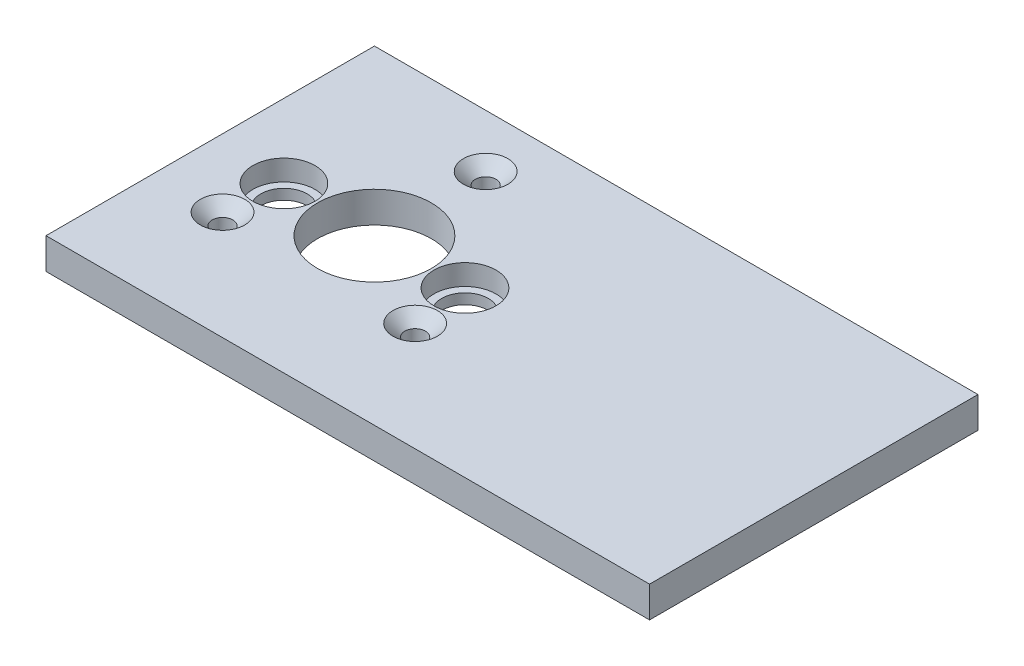
from build123d import *

# Parameters (mm, degrees)
SKETCH1_W           = 116.684502442
SKETCH1_H           = 63.5
SKETCH1_R           = 11
SKETCH1_R_2         = 2
SKETCH1_R_3         = 6
BOSS_EXTRUDE1_DEPTH = 6
CHAMFER1_SIZE       = 2.3
SKETCH2_R           = 6
SKETCH2_R_2         = 4.5
BOSS_EXTRUDE2_DEPTH = 2


with BuildPart() as part:
    # Sketch1 → Boss-Extrude1 (new body)
    with BuildSketch(Plane(origin=(0, 0, 0), x_dir=(1, 0, 0), z_dir=(0, 1, 0))):
        with Locations((26.592251221, 0)):
            Rectangle(SKETCH1_W, SKETCH1_H)
        Circle(SKETCH1_R, mode=Mode.SUBTRACT)
        with Locations((0, 21.5)):
            Circle(SKETCH1_R_2, mode=Mode.SUBTRACT)
        with Locations((18.619546181, -10.75)):
            Circle(SKETCH1_R_2, mode=Mode.SUBTRACT)
        with Locations((-18.619546181, -10.75)):
            Circle(SKETCH1_R_2, mode=Mode.SUBTRACT)
        with Locations((17.5, 0)):
            Circle(SKETCH1_R_3, mode=Mode.SUBTRACT)
        with Locations((-17.5, 0)):
            Circle(SKETCH1_R_3, mode=Mode.SUBTRACT)
    extrude(amount=BOSS_EXTRUDE1_DEPTH)

    # Chamfer1
    chamfer1_edges = [part.edges().sort_by_distance(p)[0] for p in [
        (-2, 6, -21.5),
        (16.619546181, 6, 10.75),
        (-20.619546181, 6, 10.75),
    ]]
    chamfer(chamfer1_edges, length=CHAMFER1_SIZE)

    # Sketch2 → Boss-Extrude2 (add)
    with BuildSketch(Plane.XZ):
        with Locations((-17.5, 0)):
            Circle(SKETCH2_R)
        with Locations((-17.5, 0)):
            Circle(SKETCH2_R_2, mode=Mode.SUBTRACT)
        with Locations((17.5, 0)):
            Circle(SKETCH2_R)
        with Locations((17.5, 0)):
            Circle(SKETCH2_R_2, mode=Mode.SUBTRACT)
    extrude(amount=-BOSS_EXTRUDE2_DEPTH)


solid = part.part
